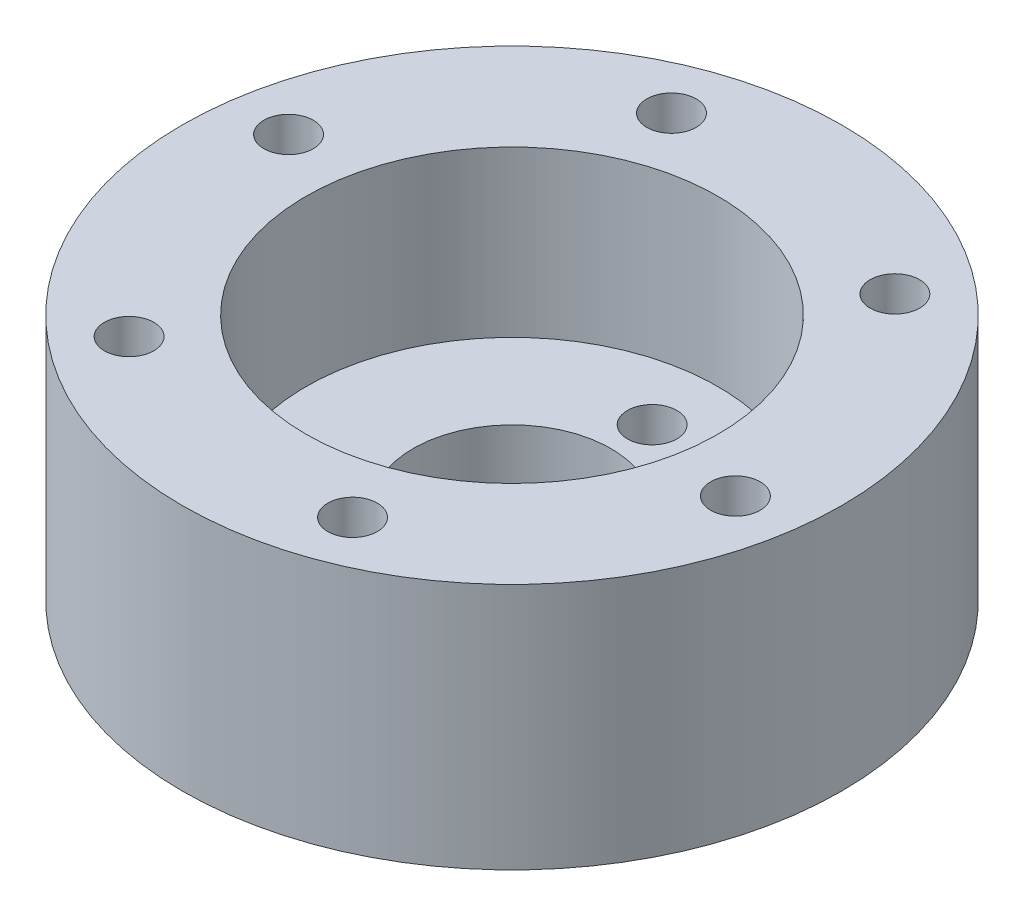
from build123d import *

# Parameters (mm, degrees)
SKETCH1_R           = 20
BOSS_EXTRUDE1_DEPTH = 15
SKETCH2_R           = 12.5
CUT_EXTRUDE1_DEPTH  = 10
SKETCH3_R           = 6
CUT_EXTRUDE2_DEPTH  = 5
SKETCH4_R           = 1.5
CUT_EXTRUDE3_DEPTH  = 15
SKETCH5_R           = 1.5
CUT_EXTRUDE4_DEPTH  = 5


with BuildPart() as part:
    # Sketch1 → Boss-Extrude1 (new body)
    with BuildSketch(Plane(origin=(0, 0, 0), x_dir=(1, 0, 0), z_dir=(0, 1, 0))):
        Circle(SKETCH1_R)
    extrude(amount=BOSS_EXTRUDE1_DEPTH)

    # Sketch2 → Cut-Extrude1 (cut)
    with BuildSketch(Plane(origin=(0, 15, 0), x_dir=(1, 0, 0), z_dir=(0, 1, 0))):
        Circle(SKETCH2_R)
    extrude(amount=-CUT_EXTRUDE1_DEPTH, mode=Mode.SUBTRACT)

    # Sketch3 → Cut-Extrude2 (cut)
    with BuildSketch(Plane(origin=(0, 5, 0), x_dir=(1, 0, 0), z_dir=(0, 1, 0))):
        Circle(SKETCH3_R)
    extrude(amount=-CUT_EXTRUDE2_DEPTH, mode=Mode.SUBTRACT)

    # Sketch4 → Cut-Extrude3 (cut)
    with BuildSketch(Plane(origin=(0, 15, 0), x_dir=(1, 0, 0), z_dir=(0, 1, 0))):
        with Locations((-10.493132047, -12.733584721)):
            Circle(SKETCH4_R)
        with Locations((-16.274173873, 2.720526557)):
            Circle(SKETCH4_R)
        with Locations((-5.781041827, 15.454111278)):
            Circle(SKETCH4_R)
        with Locations((10.493132047, 12.733584721)):
            Circle(SKETCH4_R)
        with Locations((16.274173873, -2.720526557)):
            Circle(SKETCH4_R)
        with Locations((5.781041827, -15.454111278)):
            Circle(SKETCH4_R)
    extrude(amount=-CUT_EXTRUDE3_DEPTH, mode=Mode.SUBTRACT)

    # Sketch5 → Cut-Extrude4 (cut)
    with BuildSketch(Plane.XZ):
        with Locations((0, 8.5)):
            Circle(SKETCH5_R)
        with Locations((0, -8.5)):
            Circle(SKETCH5_R)
    extrude(amount=-CUT_EXTRUDE4_DEPTH, mode=Mode.SUBTRACT)


solid = part.part
